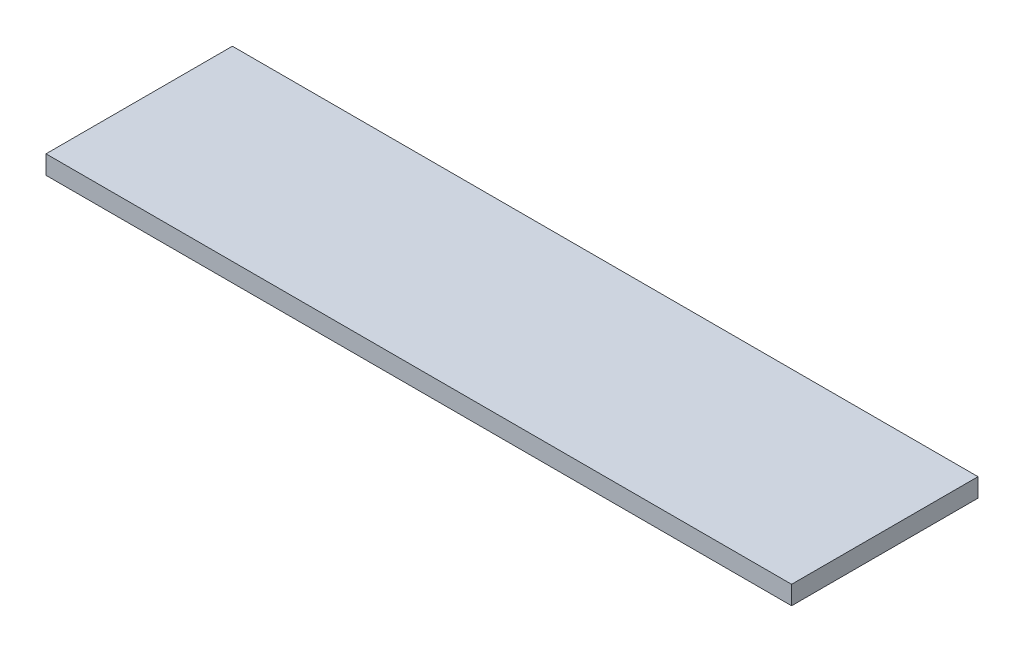
from build123d import *

# Parameters (mm, degrees)
SKETCH_2_W      = 800
SKETCH_2_H      = 200
EXTRUDE_1_DEPTH = 20


with BuildPart() as part:
    # Эскиз2 → Бобышка-Вытянуть1 (new body)
    with BuildSketch(Plane(origin=(0, 0, 0), x_dir=(1, 0, 0), z_dir=(0, 1, 0))):
        Rectangle(SKETCH_2_W, SKETCH_2_H)
    extrude(amount=EXTRUDE_1_DEPTH)


solid = part.part
